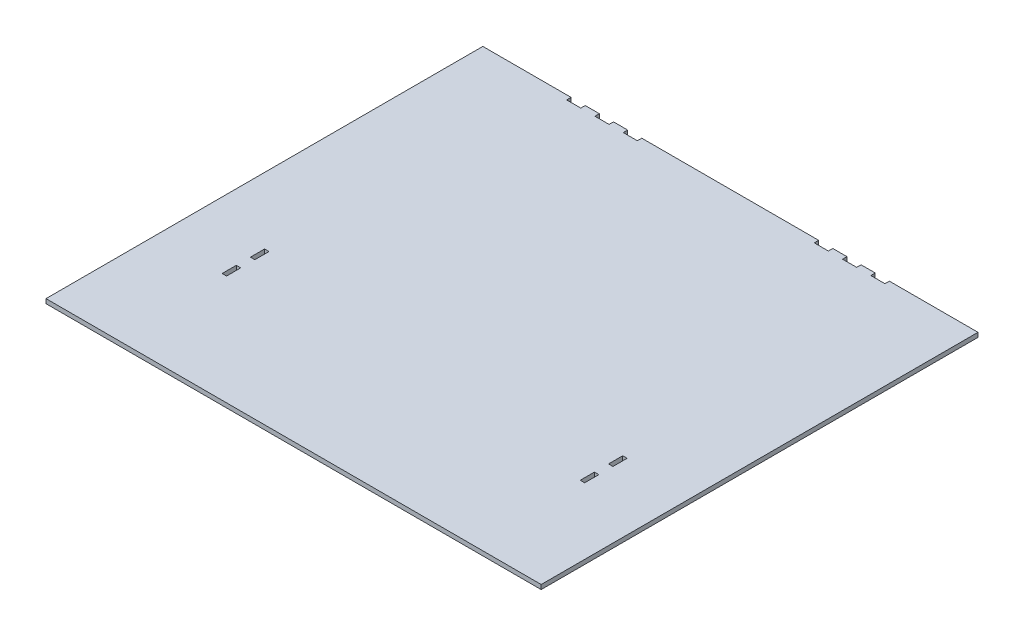
from build123d import *

# Parameters (mm, degrees)
SKETCH1_W           = 5
SKETCH1_H           = 16.000962119
BOSS_EXTRUDE1_DEPTH = 5


with BuildPart() as part:
    # Sketch1 → Boss-Extrude1 (new body)
    with BuildSketch(Plane(origin=(0, 0, 0), x_dir=(1, 0, 0), z_dir=(0, 1, 0))):
        Polygon((-280, 247), (-180.213569057, 247), (-180.213569057, 242), (-164.213569057, 242), (-164.213569057, 247), (-148.213569057, 247), (-148.213569057, 242), (-132.213569057, 242), (-132.213569057, 247), (-116.213569057, 247), (-116.213569057, 242), (-100.213569057, 242), (-100.213569057, 247), (99.786430943, 247), (99.786430943, 242), (115.786430943, 242), (115.786430943, 247), (131.786430943, 247), (131.786430943, 242), (147.786430943, 242), (147.786430943, 247), (163.786430943, 247), (163.786430943, 242), (179.786430943, 242), (179.786430943, 247), (280, 247), (280, -247), (-280, -247), align=None)
        with Locations((-202.5, -82.801443178)):
            Rectangle(SKETCH1_W, SKETCH1_H, mode=Mode.SUBTRACT)
        with Locations((202.5, -114.803367415)):
            Rectangle(SKETCH1_W, SKETCH1_H, mode=Mode.SUBTRACT)
        with Locations((202.5, -82.801443178)):
            Rectangle(SKETCH1_W, SKETCH1_H, mode=Mode.SUBTRACT)
        with Locations((-202.5, -114.803367415)):
            Rectangle(SKETCH1_W, SKETCH1_H, mode=Mode.SUBTRACT)
    extrude(amount=BOSS_EXTRUDE1_DEPTH)


solid = part.part
